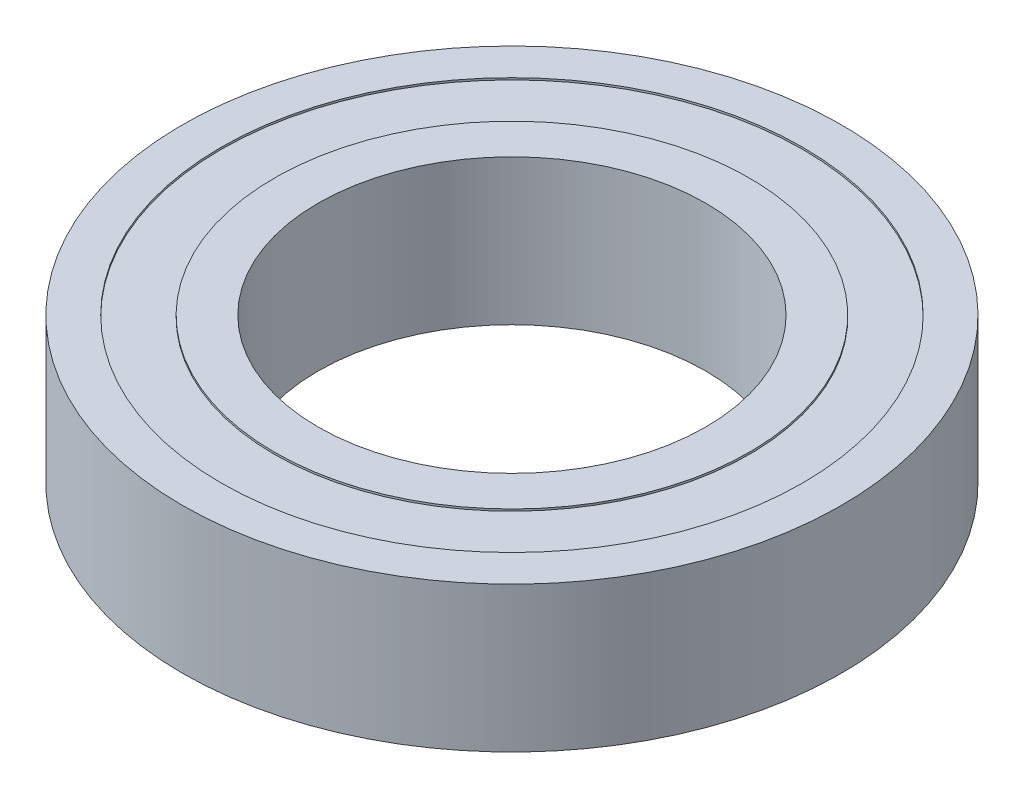
from build123d import *

# Parameters (mm, degrees)
ESQUISSE1_R             = 34
ESQUISSE1_R_2           = 20
BOSS_EXTRU_1_DEPTH      = 15
ESQUISSE2_R             = 30
ESQUISSE2_R_2           = 24.5
ENL_V_MAT_EXTRU_1_DEPTH = 0.2
ESQUISSE3_R             = 30
ESQUISSE3_R_2           = 24.5
ENL_V_MAT_EXTRU_2_DEPTH = 0.2


with BuildPart() as part:
    # Esquisse1 → Boss.-Extru.1 (new body)
    with BuildSketch(Plane(origin=(0, 0, 0), x_dir=(1, 0, 0), z_dir=(0, 1, 0))):
        Circle(ESQUISSE1_R)
        Circle(ESQUISSE1_R_2, mode=Mode.SUBTRACT)
    extrude(amount=BOSS_EXTRU_1_DEPTH)

    # Esquisse2 → Enlèv. mat.-Extru.1 (cut)
    with BuildSketch(Plane(origin=(0, 15, 0), x_dir=(1, 0, 0), z_dir=(0, 1, 0))):
        Circle(ESQUISSE2_R)
        Circle(ESQUISSE2_R_2, mode=Mode.SUBTRACT)
    extrude(amount=-ENL_V_MAT_EXTRU_1_DEPTH, mode=Mode.SUBTRACT)

    # Esquisse3 → Enlèv. mat.-Extru.2 (cut)
    with BuildSketch(Plane.XZ):
        Circle(ESQUISSE3_R)
        Circle(ESQUISSE3_R_2, mode=Mode.SUBTRACT)
    extrude(amount=-ENL_V_MAT_EXTRU_2_DEPTH, mode=Mode.SUBTRACT)


solid = part.part
